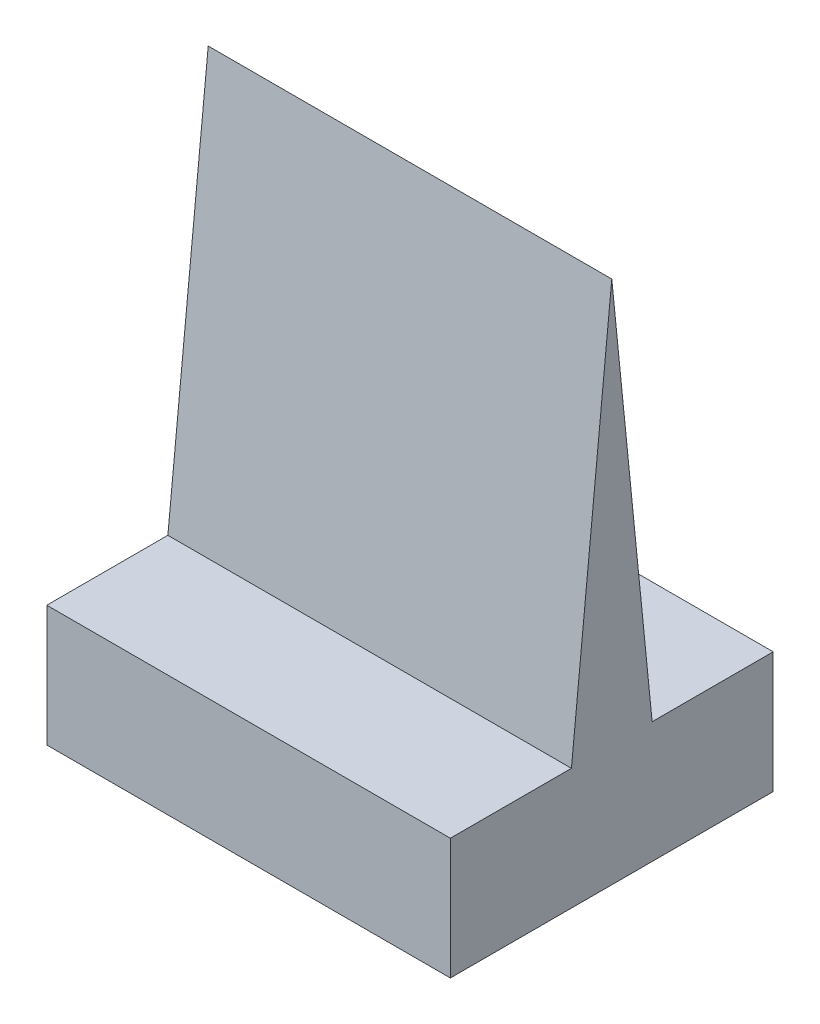
from build123d import *

# Parameters (mm, degrees)
BOSS_EXTRUDE1_DEPTH = 12.7
SKETCH2_R           = 2.54
CUT_EXTRUDE1_DEPTH  = 3.175


with BuildPart() as part:
    # Sketch1 → Boss-Extrude1 (new body)
    with BuildSketch(Plane(origin=(0, 0, 0), x_dir=(0, 0, -1), z_dir=(1, 0, 0))):
        Polygon((1.27, 3.81), (0, 16.51), (-1.27, 3.81), (-5.08, 3.81), (-5.08, 0), (5.08, 0), (5.08, 3.81), align=None)
    extrude(amount=BOSS_EXTRUDE1_DEPTH)

    # Sketch2 → Cut-Extrude1 (cut)
    with BuildSketch(Plane.XZ):
        with Locations((6.35, 0)):
            Circle(SKETCH2_R)
    extrude(amount=-CUT_EXTRUDE1_DEPTH, mode=Mode.SUBTRACT)


solid = part.part
